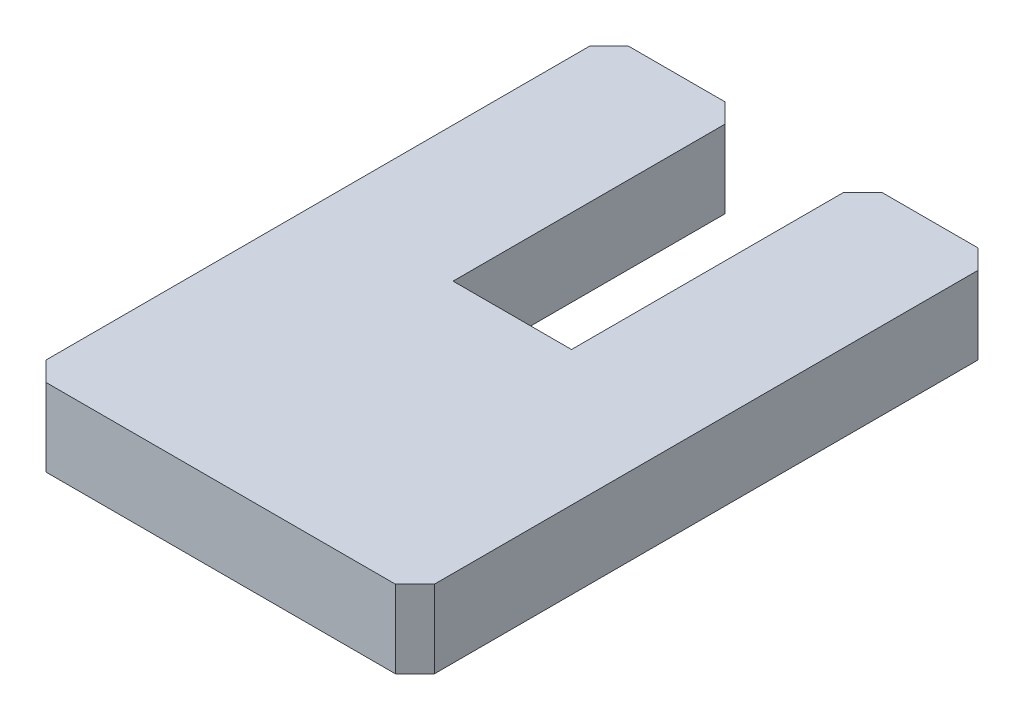
from build123d import *

# Parameters (mm, degrees)
SKIZZE1_W                       = 20
SKIZZE1_H                       = 30
AUFSATZ_LINEAR_AUSTRAGEN1_DEPTH = 4
SKIZZE2_W                       = 6.1
SKIZZE2_H                       = 15
SCHNITT_LINEAR_AUSTRAGEN1_DEPTH = 5
FASE1_SIZE                      = 1


with BuildPart() as part:
    # Skizze1 → Aufsatz-Linear austragen1 (new body)
    with BuildSketch(Plane(origin=(0, 0, 0), x_dir=(1, 0, 0), z_dir=(0, 1, 0))):
        Rectangle(SKIZZE1_W, SKIZZE1_H)
    extrude(amount=AUFSATZ_LINEAR_AUSTRAGEN1_DEPTH)

    # Skizze2 → Schnitt-Linear austragen1 (cut, through all)
    with BuildSketch(Plane(origin=(0, 4, 0), x_dir=(1, 0, 0), z_dir=(0, 1, 0))):
        with Locations((0.014627906, 7.5)):
            Rectangle(SKIZZE2_W, SKIZZE2_H)
    extrude(amount=-SCHNITT_LINEAR_AUSTRAGEN1_DEPTH, mode=Mode.SUBTRACT)

    # Fase1
    fase1_edges = [part.edges().sort_by_distance(p)[0] for p in [
        (-3.035372094, 2, -15),
        (3.064627906, 2, -15),
        (10, 2, 15),
        (-10, 2, 15),
        (-10, 2, -15),
        (10, 2, -15),
    ]]
    chamfer(fase1_edges, length=FASE1_SIZE)


solid = part.part
